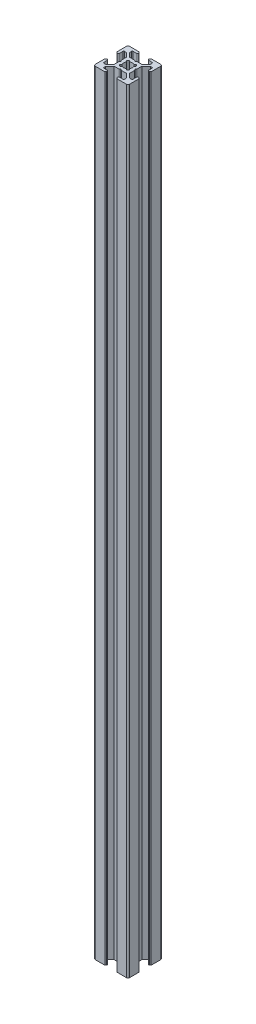
from build123d import *

# Parameters (mm, degrees)
BOSS_EXTRUDE1_DEPTH = 450
FILLET1_R           = 1
CUT_EXTRUDE1_DEPTH  = 451
FILLET2_R           = 0.5
FILLET3_R           = 0.25


with BuildPart() as part:
    # Sketch3 → Boss-Extrude1 (new body)
    with BuildSketch(Plane(origin=(0, 0, 0), x_dir=(1, 0, 0), z_dir=(0, 1, 0))):
        with BuildLine():
            Line((7, 18.5), (7, 19.5))
            ThreePointArc((7, 19.5), (6.646446609, 19.646446609), (6.5, 20))
            Line((6.5, 20), (0, 20))
            Line((0, 20), (0, 13.5))
            ThreePointArc((0, 13.5), (0.353553391, 13.353553391), (0.5, 13))
            Line((0.5, 13), (1.5, 13))
            Line((1.5, 13), (1.5, 16))
            Line((1.5, 16), (3, 16))
            Line((3, 16), (5.5, 13.5))
            Line((5.5, 13.5), (5.5, 10.5))
            Line((5.5, 10.5), (6, 10))
            Line((6, 10), (5.5, 9.5))
            Line((5.5, 9.5), (5.5, 6.5))
            Line((5.5, 6.5), (3, 4))
            Line((3, 4), (1.5, 4))
            Line((1.5, 4), (1.5, 7))
            Line((1.5, 7), (0.5, 7))
            ThreePointArc((0.5, 7), (0.353553391, 6.646446609), (0, 6.5))
            Line((0, 6.5), (0, 0))
            Line((0, 0), (6.5, 0))
            ThreePointArc((6.5, 0), (6.646446609, 0.353553391), (7, 0.5))
            Line((7, 0.5), (7, 1.5))
            Line((7, 1.5), (4, 1.5))
            Line((4, 1.5), (4, 3))
            Line((4, 3), (6.5, 5.5))
            Line((6.5, 5.5), (9.5, 5.5))
            Line((9.5, 5.5), (10, 6))
            Line((10, 6), (10.5, 5.5))
            Line((10.5, 5.5), (13.5, 5.5))
            Line((13.5, 5.5), (16, 3))
            Line((16, 3), (16, 1.5))
            Line((16, 1.5), (13, 1.5))
            Line((13, 1.5), (13, 0.5))
            ThreePointArc((13, 0.5), (13.353553391, 0.353553391), (13.5, 0))
            Line((13.5, 0), (20, 0))
            Line((20, 0), (20, 6.5))
            ThreePointArc((20, 6.5), (19.646446609, 6.646446609), (19.5, 7))
            Line((19.5, 7), (18.5, 7))
            Line((18.5, 7), (18.5, 4))
            Line((18.5, 4), (17, 4))
            Line((17, 4), (14.5, 6.5))
            Line((14.5, 6.5), (14.5, 9.5))
            Line((14.5, 9.5), (14, 10))
            Line((14, 10), (14.5, 10.5))
            Line((14.5, 10.5), (14.5, 13.5))
            Line((14.5, 13.5), (17, 16))
            Line((17, 16), (18.5, 16))
            Line((18.5, 16), (18.5, 13))
            Line((18.5, 13), (19.5, 13))
            ThreePointArc((19.5, 13), (19.646446609, 13.353553391), (20, 13.5))
            Line((20, 13.5), (20, 20))
            Line((20, 20), (13.5, 20))
            ThreePointArc((13.5, 20), (13.353553391, 19.646446609), (13, 19.5))
            Line((13, 19.5), (13, 18.5))
            Line((13, 18.5), (16, 18.5))
            Line((16, 18.5), (16, 17))
            Line((16, 17), (13.5, 14.5))
            Line((13.5, 14.5), (10.5, 14.5))
            Line((10.5, 14.5), (10, 14))
            Line((10, 14), (9.5, 14.5))
            Line((9.5, 14.5), (6.5, 14.5))
            Line((6.5, 14.5), (4, 17))
            Line((4, 17), (4, 18.5))
            Line((4, 18.5), (7, 18.5))
        make_face()
    extrude(amount=BOSS_EXTRUDE1_DEPTH)

    # Fillet1
    fillet1_edges = [part.edges().sort_by_distance(p)[0] for p in [
        (20, 225, 0),
        (0, 225, 0),
        (0, 225, -20),
        (20, 225, -20),
    ]]
    fillet(fillet1_edges, radius=FILLET1_R)

    # Sketch4 → Cut-Extrude1 (cut, through all)
    with BuildSketch(Plane(origin=(0, 450, 0), x_dir=(1, 0, 0), z_dir=(0, 1, 0))):
        with BuildLine():
            Line((10, 11), (11.195582496, 12.195582496))
            ThreePointArc((11.195582496, 12.195582496), (10, 12.5), (8.804417504, 12.195582496))
            Line((8.804417504, 12.195582496), (10, 11))
        make_face()
        with BuildLine():
            ThreePointArc((12.195582496, 11.195582496), (11.767766953, 11.767766953), (11.195582496, 12.195582496))
            Line((11.195582496, 12.195582496), (10, 11))
            Line((10, 11), (11, 10))
            Line((11, 10), (12.195582496, 11.195582496))
        make_face()
        with BuildLine():
            Line((9, 10), (10, 11))
            Line((10, 11), (8.804417504, 12.195582496))
            ThreePointArc((8.804417504, 12.195582496), (8.232233047, 11.767766953), (7.804417504, 11.195582496))
            Line((7.804417504, 11.195582496), (9, 10))
        make_face()
        Polygon((11, 10), (10, 11), (9, 10), (10, 9), align=None)
        with BuildLine():
            Line((7.804417504, 8.804417504), (9, 10))
            Line((9, 10), (7.804417504, 11.195582496))
            ThreePointArc((7.804417504, 11.195582496), (7.5, 10), (7.804417504, 8.804417504))
        make_face()
        with BuildLine():
            Line((10, 9), (9, 10))
            Line((9, 10), (7.804417504, 8.804417504))
            ThreePointArc((7.804417504, 8.804417504), (8.232233047, 8.232233047), (8.804417504, 7.804417504))
            Line((8.804417504, 7.804417504), (10, 9))
        make_face()
        with BuildLine():
            Line((11.195582496, 7.804417504), (10, 9))
            Line((10, 9), (8.804417504, 7.804417504))
            ThreePointArc((8.804417504, 7.804417504), (10, 7.5), (11.195582496, 7.804417504))
        make_face()
        with BuildLine():
            Line((12.195582496, 8.804417504), (11, 10))
            Line((11, 10), (10, 9))
            Line((10, 9), (11.195582496, 7.804417504))
            ThreePointArc((11.195582496, 7.804417504), (11.767766953, 8.232233047), (12.195582496, 8.804417504))
        make_face()
        with BuildLine():
            ThreePointArc((12.5, 10), (12.422700584, 10.616864556), (12.195582496, 11.195582496))
            Line((12.195582496, 11.195582496), (11, 10))
            Line((11, 10), (12.195582496, 8.804417504))
            ThreePointArc((12.195582496, 8.804417504), (12.422700584, 9.383135444), (12.5, 10))
        make_face()
        with BuildLine():
            ThreePointArc((8.804417504, 7.804417504), (8.232233047, 8.232233047), (7.804417504, 8.804417504))
            Line((7.804417504, 8.804417504), (7, 8))
            Line((7, 8), (8, 7))
            Line((8, 7), (8.804417504, 7.804417504))
        make_face()
        with BuildLine():
            Line((13, 8), (12.195582496, 8.804417504))
            ThreePointArc((12.195582496, 8.804417504), (11.767766953, 8.232233047), (11.195582496, 7.804417504))
            Line((11.195582496, 7.804417504), (12, 7))
            Line((12, 7), (13, 8))
        make_face()
        with BuildLine():
            Line((13, 12), (12, 13))
            Line((12, 13), (11.195582496, 12.195582496))
            ThreePointArc((11.195582496, 12.195582496), (11.767766953, 11.767766953), (12.195582496, 11.195582496))
            Line((12.195582496, 11.195582496), (13, 12))
        make_face()
        with BuildLine():
            ThreePointArc((7.804417504, 11.195582496), (8.232233047, 11.767766953), (8.804417504, 12.195582496))
            Line((8.804417504, 12.195582496), (8, 13))
            Line((8, 13), (7, 12))
            Line((7, 12), (7.804417504, 11.195582496))
        make_face()
    extrude(amount=-CUT_EXTRUDE1_DEPTH, mode=Mode.SUBTRACT)

    # Fillet2
    fillet2_edges = [part.edges().sort_by_distance(p)[0] for p in [
        (18.5, 225, -13),
        (18.5, 225, -16),
        (14.5, 225, -10.5),
        (14.5, 225, -9.5),
        (18.5, 225, -4),
        (18.5, 225, -7),
        (13, 225, -1.5),
        (16, 225, -1.5),
        (10.5, 225, -5.5),
        (9.5, 225, -5.5),
        (4, 225, -1.5),
        (7, 225, -1.5),
        (1.5, 225, -7),
        (1.5, 225, -4),
        (5.5, 225, -9.5),
        (5.5, 225, -10.5),
        (1.5, 225, -16),
        (1.5, 225, -13),
        (7, 225, -18.5),
        (4, 225, -18.5),
        (9.5, 225, -14.5),
        (10.5, 225, -14.5),
        (16, 225, -18.5),
        (13, 225, -18.5),
    ]]
    fillet(fillet2_edges, radius=FILLET2_R)

    # Fillet3
    fillet3_edges = [part.edges().sort_by_distance(p)[0] for p in [
        (7, 225, -12),
        (8, 225, -13),
        (12, 225, -13),
        (13, 225, -12),
        (13, 225, -8),
        (12, 225, -7),
        (8, 225, -7),
        (7, 225, -8),
    ]]
    fillet(fillet3_edges, radius=FILLET3_R)


solid = part.part
